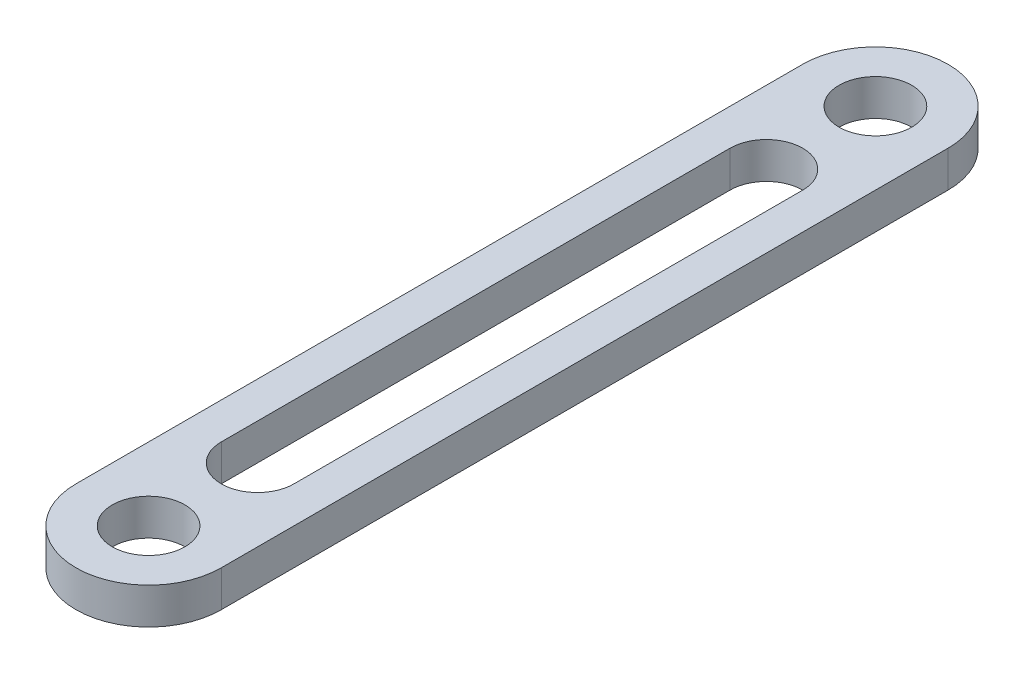
from build123d import *

# Parameters (mm, degrees)
SKETCH1_R           = 5
BOSS_EXTRUDE1_DEPTH = 5


with BuildPart() as part:
    # Sketch1 → Boss-Extrude1 (new body)
    with BuildSketch(Plane(origin=(0, 0, 0), x_dir=(1, 0, 0), z_dir=(0, 1, 0))):
        with BuildLine():
            Line((-10, 0), (-10, 100))
            ThreePointArc((-10, 100), (0, 110), (10, 100))
            Line((10, 100), (10, 0))
            ThreePointArc((10, 0), (0, -10), (-10, 0))
        make_face()
        Circle(SKETCH1_R, mode=Mode.SUBTRACT)
        with Locations((0, 100)):
            Circle(SKETCH1_R, mode=Mode.SUBTRACT)
        with BuildLine():
            Line((5, 85), (5, 15))
            ThreePointArc((5, 15), (0, 10), (-5, 15))
            Line((-5, 15), (-5, 85))
            ThreePointArc((-5, 85), (0, 90), (5, 85))
        make_face(mode=Mode.SUBTRACT)
    extrude(amount=BOSS_EXTRUDE1_DEPTH)


solid = part.part
